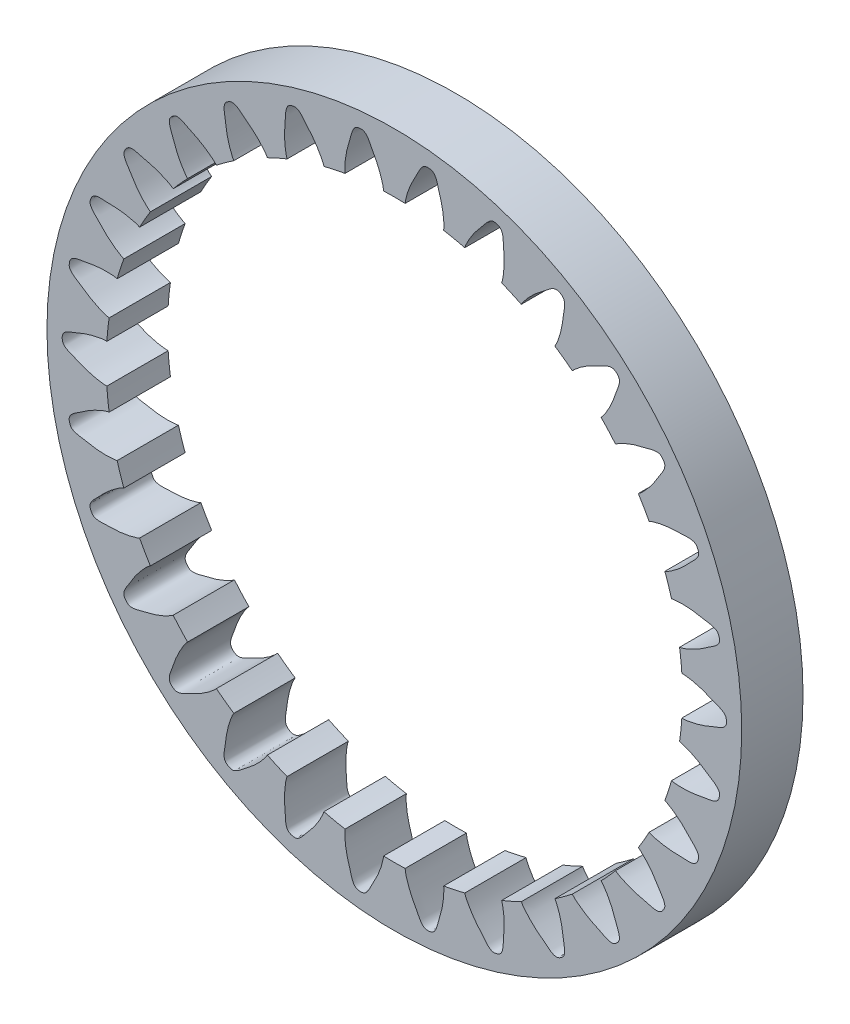
from build123d import *

# Parameters (mm, degrees)
SKETCHREVOLVERING_GEAR_FIXED01_W       = 3
SKETCHREVOLVERING_GEAR_FIXED01_H       = 2.9
TOOTHEXTRUDECUTRING_GEAR_FIXED01_DEPTH = 2.5
PATTERNRING_GEAR_FIXED01_COUNT         = 30


with BuildPart() as part:
    # SketchRevolveRing_Gear_Fixed01 → Ring_Gear_Fixed01 (revolve)
    with BuildSketch(Plane(origin=(0, 0, 0), x_dir=(0, 0, -1), z_dir=(1, 0, 0))):
        with Locations((0, 15.55)):
            Rectangle(SKETCHREVOLVERING_GEAR_FIXED01_W, SKETCHREVOLVERING_GEAR_FIXED01_H)
    revolve(axis=Axis((0, 0, 0), (0, 0, -1)))

    # SketchToothRing_Gear_Fixed01 → ToothExtrudeCutRing_Gear_Fixed01 (cut, symmetric)
    with BuildSketch(Plane.XY):
        with BuildLine():
            ThreePointArc((14.063513962, -0.947401144), (14.0953891, 0), (14.063513962, 0.947401144))
            add(Edge.make_bspline(
                [(14.063513962, 0.947401144), (14.127616634, 0.950372711), (14.305929506, 0.937767546), (14.650440571, 0.880584034), (15.148304557, 0.746205064), (15.646271442, 0.522341635), (16.047719151, 0.379333707), (16.22633565, 0.204429341), (16.256546722, 0.045803537), (16.256377333, -0.100520378), (16.211045111, -0.21075486), (16.069725121, -0.378867535), (15.653263916, -0.514093356), (15.149354996, -0.748165119), (14.588267217, -0.893365777), (14.241576197, -0.955655463), (14.063513962, -0.947401144)],
                knots=[0, 0, 0, 0, 0.038206472, 0.106128647, 0.20801187, 0.343856151, 0.432946016, 0.457131319, 0.488936568, 0.526745146, 0.542868681, 0.558992217, 0.656143849, 0.79198813, 0.893871353, 1, 1, 1, 1], degree=3))
        make_face()
    toothextrudecutring_gear_fixed01 = extrude(amount=TOOTHEXTRUDECUTRING_GEAR_FIXED01_DEPTH, both=True, mode=Mode.SUBTRACT)

    # PatternRing_Gear_Fixed01: ToothExtrudeCutRing_Gear_Fixed01 ×30 about axis
    patternring_gear_fixed01_axis = Axis((0, 0, 50), (0, 0, -1))
    for i in range(1, PATTERNRING_GEAR_FIXED01_COUNT):
        add(toothextrudecutring_gear_fixed01.rotate(patternring_gear_fixed01_axis, i * 360 / PATTERNRING_GEAR_FIXED01_COUNT), mode=Mode.SUBTRACT)


solid = part.part
